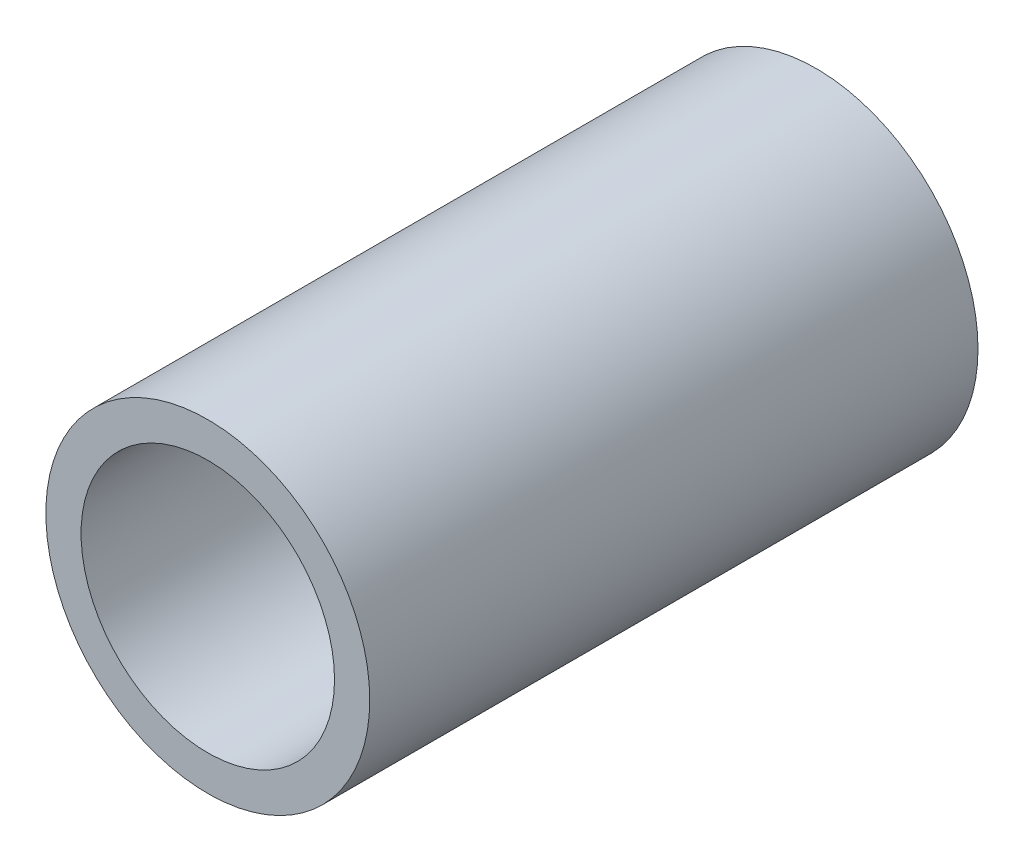
from build123d import *

# Parameters (mm, degrees)
SKETCH1_R           = 15.975
SKETCH1_R_2         = 12.5
BOSS_EXTRUDE1_DEPTH = 60


with BuildPart() as part:
    # Sketch1 → Boss-Extrude1 (new body)
    with BuildSketch(Plane.XY):
        with Locations((-7.473500512, 0)):
            Circle(SKETCH1_R)
        with Locations((-7.473500512, 0)):
            Circle(SKETCH1_R_2, mode=Mode.SUBTRACT)
    extrude(amount=BOSS_EXTRUDE1_DEPTH)


solid = part.part
